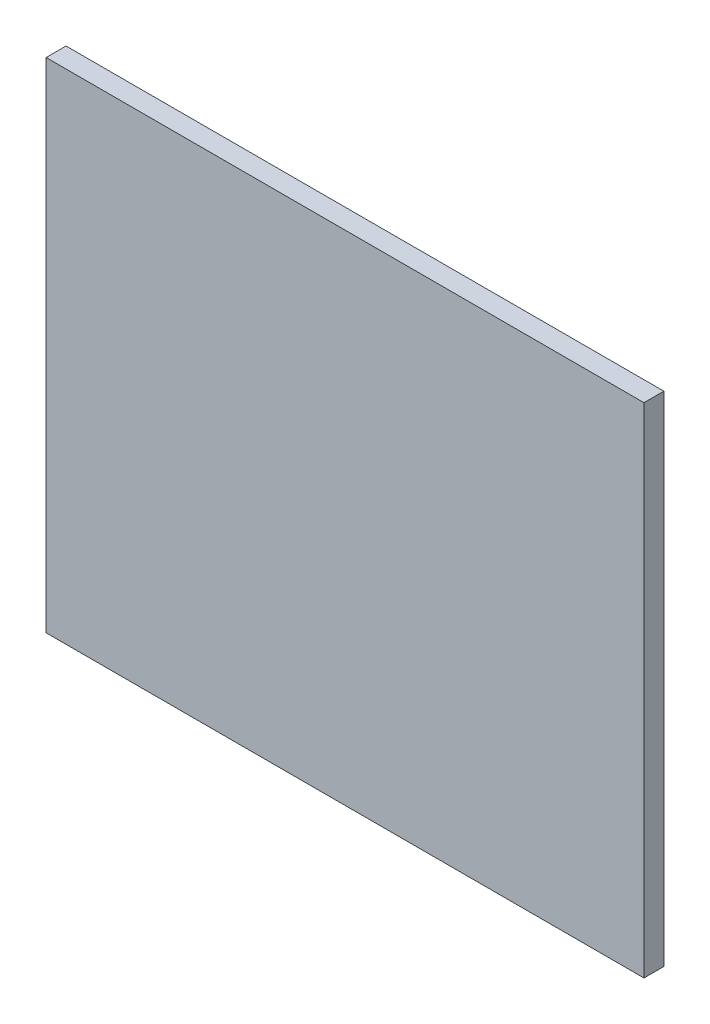
from build123d import *

# Parameters (mm, degrees)
SKETCH1_W           = 150
SKETCH1_H           = 125
BOSS_EXTRUDE1_DEPTH = 5


with BuildPart() as part:
    # Sketch1 → Boss-Extrude1 (new body)
    with BuildSketch(Plane.XY):
        with Locations((75, 62.5)):
            Rectangle(SKETCH1_W, SKETCH1_H)
    extrude(amount=-BOSS_EXTRUDE1_DEPTH)


solid = part.part
